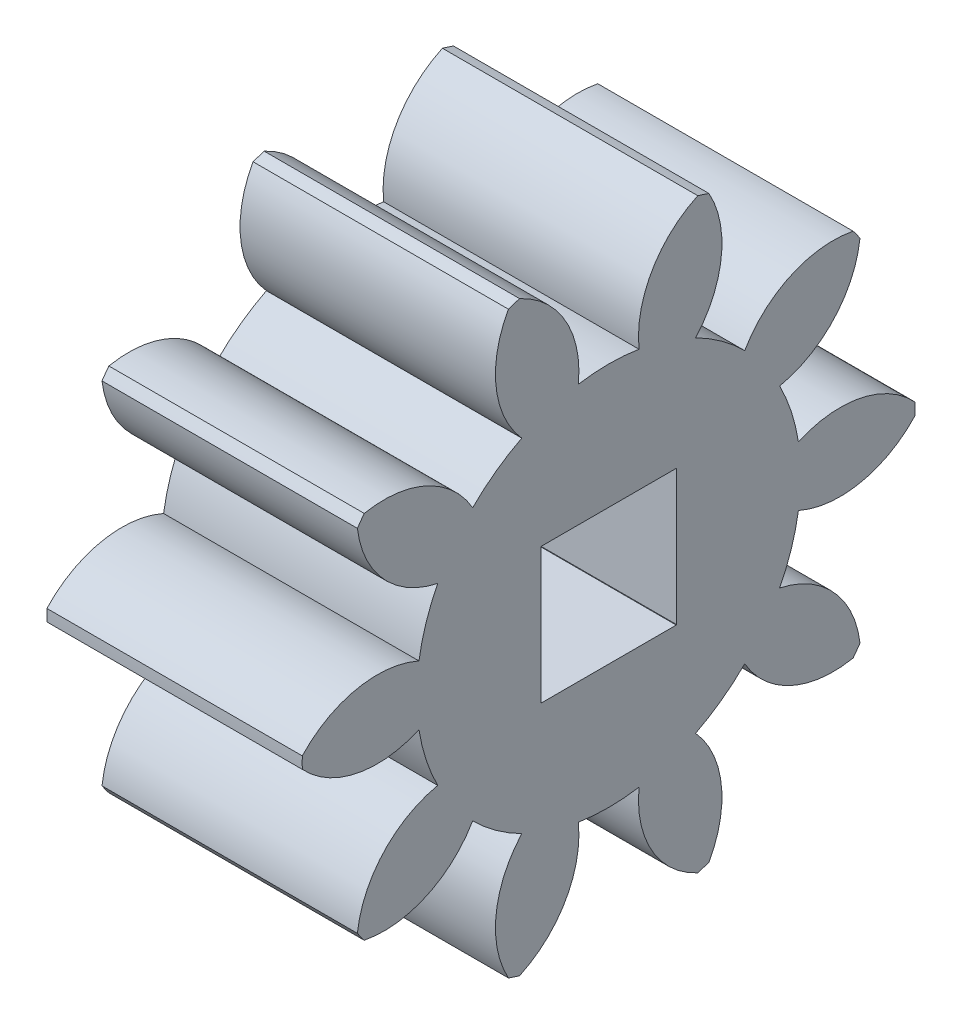
from build123d import *

# Parameters (mm, degrees)
BASPROSKE_W         = 6.35
BASPROSKE_H         = 7.62
TOOTHCUT_DEPTH      = 13.508049408
TEETHCUTS_COUNT     = 10
TEETHCUTS_ANGLE     = 324
BORSKE_R            = 2.38125
BORE_DEPTH          = 50.8000508
BOSS_EXTRUDE1_DEPTH = 6.35


with BuildPart() as part:
    # BasProSke → Base-Revolve (revolve)
    with BuildSketch(Plane(origin=(0, 0, 0), x_dir=(1, 0, 0), z_dir=(0, 1, 0)), mode=Mode.PRIVATE) as base_revolve_sk:
        with Locations((3.175, 3.81)):
            Rectangle(BASPROSKE_W, BASPROSKE_H)
    revolve(base_revolve_sk.sketch.rotate(Axis((-10, 0, 0), (1, 0, 0)), 180), axis=Axis((-10, 0, 0), (1, 0, 0)))

    # TooCutSke → ToothCut (cut, through all)
    with BuildSketch(Plane(origin=(0, 0, 0), x_dir=(0, 0, -1), z_dir=(1, 0, 0))):
        with BuildLine():
            ThreePointArc((0.754581835, 4.715203208), (0, 4.7752), (-0.754581835, 4.715203208))
            ThreePointArc((-0.754581835, 4.715203208), (-1.08060133, 6.254605234), (-2.250824617, 7.306567573))
            ThreePointArc((-2.250824617, 7.306567573), (0, 7.6454), (2.250824617, 7.306567573))
            ThreePointArc((2.250824617, 7.306567573), (1.08060133, 6.254605234), (0.754581835, 4.715203208))
        make_face()
    toothcut = extrude(amount=TOOTHCUT_DEPTH, mode=Mode.SUBTRACT)

    # TeethCuts: ToothCut ×10 about axis
    teethcuts_axis = Axis((-10, 0, 0), (1, 0, 0))
    for i in range(1, TEETHCUTS_COUNT):
        add(toothcut.rotate(teethcuts_axis, i * TEETHCUTS_ANGLE / (TEETHCUTS_COUNT - 1)), mode=Mode.SUBTRACT)

    # BorSke → Bore (cut, symmetric)
    with BuildSketch(Plane(origin=(0, 0, 0), x_dir=(0, 0, -1), z_dir=(1, 0, 0))):
        with Locations(Location((0, 0, 0), (0, 0, 180))):
            Circle(BORSKE_R)
    extrude(amount=BORE_DEPTH, both=True, mode=Mode.SUBTRACT)

    # Sketch1 → Boss-Extrude1 (add)
    with BuildSketch(Plane(origin=(6.35, 0, 0), x_dir=(0, 0, -1), z_dir=(1, 0, 0))):
        with BuildLine():
            Line((-1.680087888, 1.6875), (1.680087888, 1.6875))
            ThreePointArc((1.680087888, 1.6875), (0, 2.38125), (-1.680087888, 1.6875))
        make_face()
        with BuildLine():
            ThreePointArc((-1.6875, 1.680087888), (-2.38125, 0), (-1.6875, -1.680087888))
            Line((-1.6875, -1.680087888), (-1.6875, 1.680087888))
        make_face()
        with BuildLine():
            ThreePointArc((-1.680087888, -1.6875), (0, -2.38125), (1.680087888, -1.6875))
            Line((1.680087888, -1.6875), (-1.680087888, -1.6875))
        make_face()
        with BuildLine():
            Line((1.6875, 1.680087888), (1.6875, -1.680087888))
            ThreePointArc((1.6875, -1.680087888), (2.200989657, -0.908843272), (2.38125, 0))
            ThreePointArc((2.38125, 0), (2.200989657, 0.908843272), (1.6875, 1.680087888))
        make_face()
    extrude(amount=-BOSS_EXTRUDE1_DEPTH)


solid = part.part
